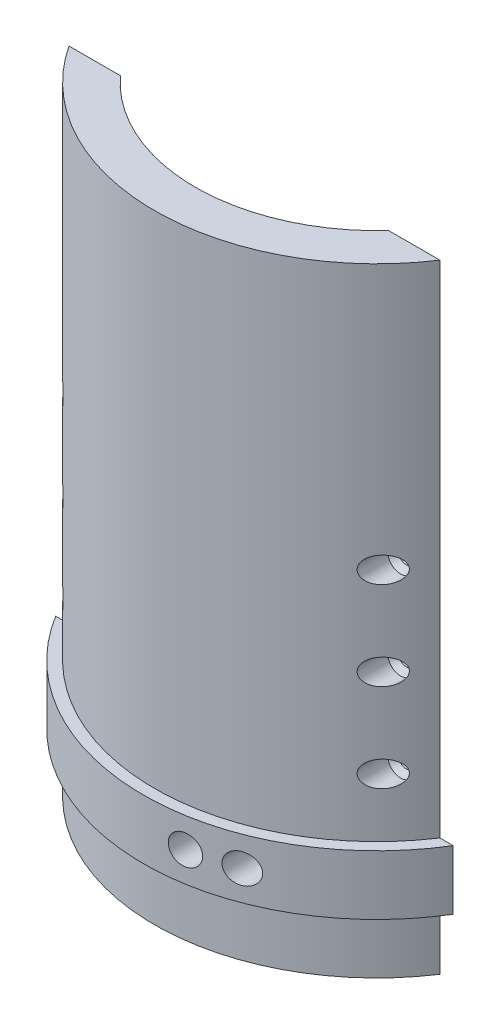
from build123d import *

# Parameters (mm, degrees)
BOSS_EXTRUDE1_DEPTH      = 100
LPATTERN1_COUNT          = 4
LPATTERN1_PITCH          = 20
BOSS_EXTRUDE2_DEPTH      = 6.731
BOSS_EXTRUDE2_DEPTH_BACK = 6.731
SKETCH9_R                = 3.334469726
CUT_EXTRUDE1_DEPTH       = 34
BOSS_EXTRUDE3_DEPTH      = 40


with BuildPart() as part:
    # Sketch1 → Boss-Extrude1 (new body)
    with BuildSketch(Plane(origin=(60.535204745, 0, -85.948449604), x_dir=(1, 0, 0), z_dir=(0, 1, 0))):
        with BuildLine():
            ThreePointArc((-30.186446753, -113.644462538), (-60.535204745, -127.035141416), (-90.883962736, -113.644462538))
            Line((-90.883962736, -113.644462538), (-102.513962844, -113.644462538))
            ThreePointArc((-102.513962844, -113.644462538), (-60.535204745, -136.240449604), (-18.556446645, -113.644462538))
            Line((-18.556446645, -113.644462538), (-30.186446753, -113.644462538))
        make_face()
    extrude(amount=BOSS_EXTRUDE1_DEPTH)

    # Sketch6 → Cut-Revolve4 (revolve, cut)
    with BuildSketch(Plane(origin=(36.163758045, 20, 27.696012934), x_dir=(-1, 0, 0), z_dir=(0, -1, 0))):
        Polygon((0, 1.685394277), (0, -4.78184701), (0, -15.185924704), (-2.9, -15.185924704), (-2.9, -3.079025683), (-1.65, -1.881964943), (-1.65, 1.685394277), align=None)
    cut_revolve4 = revolve(axis=Axis((36.163758045, 20, 26.010618657), (0, 0, 1)), mode=Mode.SUBTRACT)

    # LPattern1: Cut-Revolve4 ×4
    with Locations(*[(0, i * LPATTERN1_PITCH, 0) for i in range(1, LPATTERN1_COUNT)]):
        add(cut_revolve4, mode=Mode.SUBTRACT)

    # Mirror1: Cut-Revolve4 across plane
    add(cut_revolve4.mirror(Plane(origin=(0, 0, 0), x_dir=(0, 0, 1), z_dir=(1, 0, 0))), mode=Mode.SUBTRACT)

    # Mirror1 copy 1 sketch → Mirror1 copy 1 (revolve, cut)
    with BuildSketch(Plane(origin=(-36.163758045, 40, 27.696012934), x_dir=(1, 0, 0), z_dir=(0, -1, 0))):
        Polygon((0, -1.685394277), (0, 4.78184701), (0, 15.185924704), (-2.9, 15.185924704), (-2.9, 3.079025683), (-1.65, 1.881964943), (-1.65, -1.685394277), align=None)
    revolve(axis=Axis((-36.163758045, 40, 26.010618657), (0, 0, -1)), mode=Mode.SUBTRACT)

    # Mirror1 copy 2 sketch → Mirror1 copy 2 (revolve, cut)
    with BuildSketch(Plane(origin=(-36.163758045, 60, 27.696012934), x_dir=(1, 0, 0), z_dir=(0, -1, 0))):
        Polygon((0, -1.685394277), (0, 4.78184701), (0, 15.185924704), (-2.9, 15.185924704), (-2.9, 3.079025683), (-1.65, 1.881964943), (-1.65, -1.685394277), align=None)
    revolve(axis=Axis((-36.163758045, 60, 26.010618657), (0, 0, -1)), mode=Mode.SUBTRACT)

    # Mirror1 copy 3 sketch → Mirror1 copy 3 (revolve, cut)
    with BuildSketch(Plane(origin=(-36.163758045, 80, 27.696012934), x_dir=(1, 0, 0), z_dir=(0, -1, 0))):
        Polygon((0, -1.685394277), (0, 4.78184701), (0, 15.185924704), (-2.9, 15.185924704), (-2.9, 3.079025683), (-1.65, 1.881964943), (-1.65, -1.685394277), align=None)
    revolve(axis=Axis((-36.163758045, 80, 26.010618657), (0, 0, -1)), mode=Mode.SUBTRACT)

    # Sketch7 → Boss-Extrude2 (add, two sides)
    with BuildSketch(Plane(origin=(0, 20, 0), x_dir=(-1, 0, 0), z_dir=(0, -1, 0))) as boss_extrude2_sk:
        with BuildLine():
            Line((-44.990566695, -27.696012934), (-41.978758099, -27.696012934))
            ThreePointArc((-41.978758099, -27.696012934), (0, -50.292), (41.978758099, -27.696012934))
            Line((41.978758099, -27.696012934), (44.990566695, -27.696012934))
            ThreePointArc((44.990566695, -27.696012934), (0, -52.832), (-44.990566695, -27.696012934))
        make_face()
    extrude(amount=BOSS_EXTRUDE2_DEPTH)
    extrude(boss_extrude2_sk.sketch, amount=-BOSS_EXTRUDE2_DEPTH_BACK)

    # Sketch9 → Cut-Extrude1 (cut)
    with BuildSketch(Plane(origin=(0, 0, 27.696012934), x_dir=(-1, 0, 0), z_dir=(0, 0, -1))):
        with Locations((-18.801989508, 20)):
            Circle(SKETCH9_R)
        with Locations((-8.69556827, 20)):
            Circle(SKETCH9_R)
    extrude(amount=-CUT_EXTRUDE1_DEPTH, mode=Mode.SUBTRACT)

    # Sketch10 → Boss-Extrude3 (add)
    with BuildSketch(Plane(origin=(0, 100, 0), x_dir=(1, 0, 0), z_dir=(0, 1, 0))):
        with BuildLine():
            Line((-30.348757991, -27.696012934), (-41.978758099, -27.696012934))
            ThreePointArc((-41.978758099, -27.696012934), (0, -50.292), (41.978758099, -27.696012934))
            Line((41.978758099, -27.696012934), (30.348757991, -27.696012934))
            ThreePointArc((30.348757991, -27.696012934), (0, -41.086691812), (-30.348757991, -27.696012934))
        make_face()
    extrude(amount=BOSS_EXTRUDE3_DEPTH)


solid = part.part
